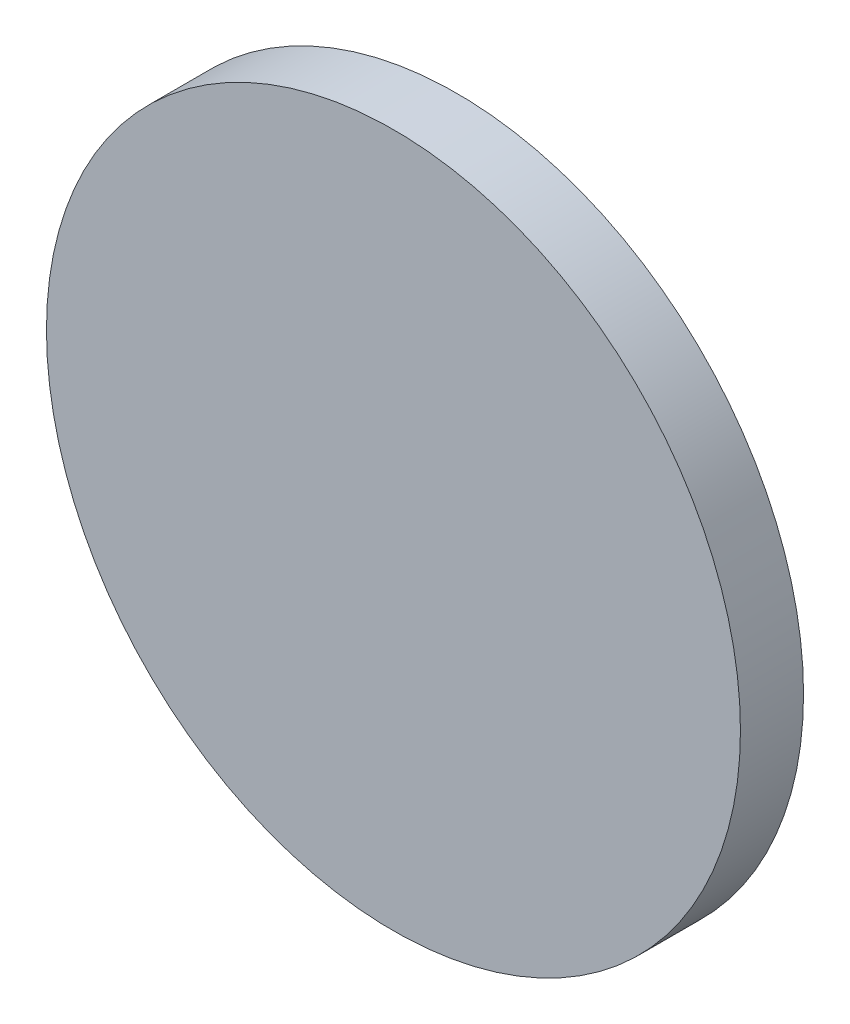
from build123d import *

# Parameters (mm, degrees)
SKETCH1_R           = 11
BOSS_EXTRUDE1_DEPTH = 2


with BuildPart() as part:
    # Sketch1 → Boss-Extrude1 (new body)
    with BuildSketch(Plane.XY):
        with Locations((0, -17.75)):
            Circle(SKETCH1_R)
    extrude(amount=BOSS_EXTRUDE1_DEPTH)


solid = part.part
